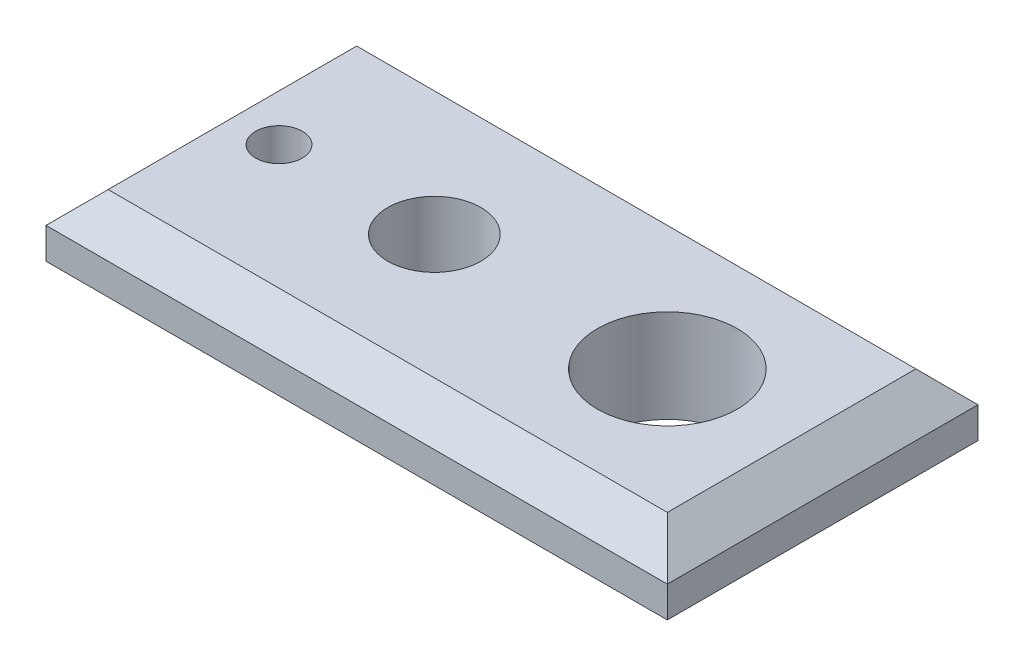
from build123d import *

# Parameters (mm, degrees)
IZIM1_W                     = 200
IZIM1_H                     = 100
Y_KSEKLIK_EKSTR_ZYON1_DEPTH = 30
PAH1_SIZE                   = 10
IZIM2_R                     = 7.5
IZIM2_R_2                   = 15
IZIM2_R_3                   = 22.5
KES_EKSTR_ZYON1_DEPTH       = 31


with BuildPart() as part:
    # Çizim1 → Yükseklik-Ekstrüzyon1 (new body)
    with BuildSketch(Plane(origin=(0, 0, 0), x_dir=(1, 0, 0), z_dir=(0, 1, 0))):
        with Locations((-100, 50)):
            Rectangle(IZIM1_W, IZIM1_H)
    extrude(amount=Y_KSEKLIK_EKSTR_ZYON1_DEPTH)

    # Pah1
    pah1_edges = [part.edges().sort_by_distance(p)[0] for p in [
        (-200, 30, -50),
        (-100, 30, 0),
        (0, 30, -50),
        (-100, 0, 0),
        (-200, 0, -50),
        (-100, 0, -100),
        (0, 0, -50),
        (-100, 30, -100),
    ]]
    chamfer(pah1_edges, length=PAH1_SIZE)

    # Çizim2 → Kes-Ekstrüzyon1 (cut, through all)
    with BuildSketch(Plane(origin=(0, 30, 0), x_dir=(1, 0, 0), z_dir=(0, 1, 0))):
        with Locations((-175, 50)):
            Circle(IZIM2_R)
        with Locations((-125, 50)):
            Circle(IZIM2_R_2)
        with Locations((-50, 50)):
            Circle(IZIM2_R_3)
    extrude(amount=-KES_EKSTR_ZYON1_DEPTH, mode=Mode.SUBTRACT)


solid = part.part
